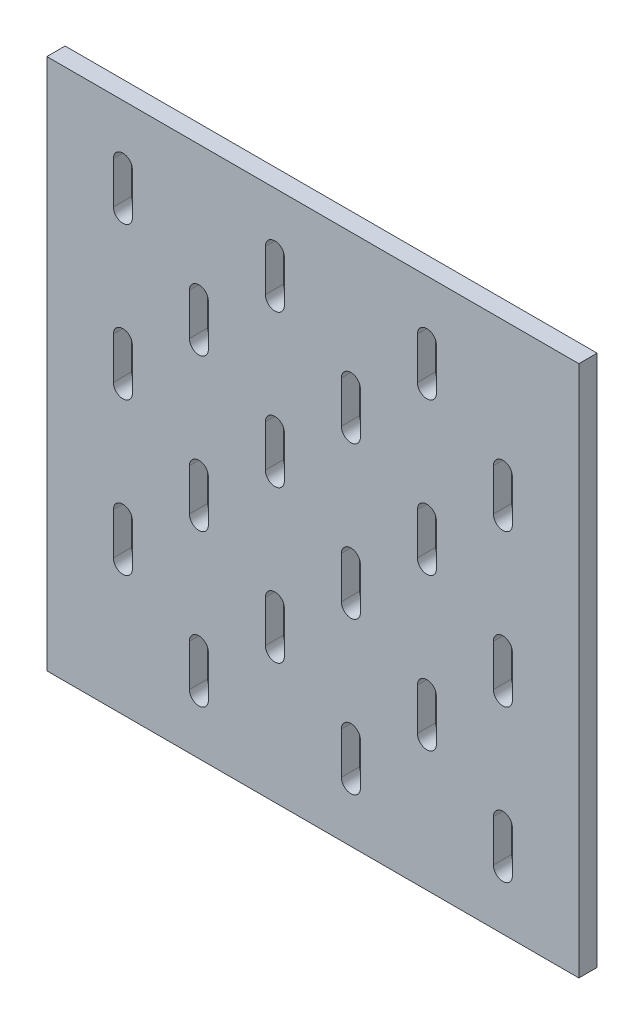
from build123d import *

# Parameters (mm, degrees)
SKETCH_1_W      = 350
SKETCH_1_H      = 350
EXTRUDE_1_DEPTH = 12


with BuildPart() as part:
    # Эскиз1 → Бобышка-Вытянуть1 (new body)
    with BuildSketch(Plane.XY):
        with Locations((75, 125)):
            Rectangle(SKETCH_1_W, SKETCH_1_H)
        with BuildLine():
            Line((6.25, 13.75), (6.25, -13.75))
            ThreePointArc((6.25, -13.75), (0, -20), (-6.25, -13.75))
            Line((-6.25, -13.75), (-6.25, 13.75))
            ThreePointArc((-6.25, 13.75), (0, 20), (6.25, 13.75))
        make_face(mode=Mode.SUBTRACT)
        with BuildLine():
            Line((-43.75, 63.75), (-43.75, 36.25))
            ThreePointArc((-43.75, 36.25), (-50, 30), (-56.25, 36.25))
            Line((-56.25, 36.25), (-56.25, 63.75))
            ThreePointArc((-56.25, 63.75), (-50, 70), (-43.75, 63.75))
        make_face(mode=Mode.SUBTRACT)
        with BuildLine():
            Line((106.25, 13.75), (106.25, -13.75))
            ThreePointArc((106.25, -13.75), (100, -20), (93.75, -13.75))
            Line((93.75, -13.75), (93.75, 13.75))
            ThreePointArc((93.75, 13.75), (100, 20), (106.25, 13.75))
        make_face(mode=Mode.SUBTRACT)
        with BuildLine():
            Line((56.25, 63.75), (56.25, 36.25))
            ThreePointArc((56.25, 36.25), (50, 30), (43.75, 36.25))
            Line((43.75, 36.25), (43.75, 63.75))
            ThreePointArc((43.75, 63.75), (50, 70), (56.25, 63.75))
        make_face(mode=Mode.SUBTRACT)
        with BuildLine():
            Line((206.25, 13.75), (206.25, -13.75))
            ThreePointArc((206.25, -13.75), (200, -20), (193.75, -13.75))
            Line((193.75, -13.75), (193.75, 13.75))
            ThreePointArc((193.75, 13.75), (200, 20), (206.25, 13.75))
        make_face(mode=Mode.SUBTRACT)
        with BuildLine():
            Line((156.25, 63.75), (156.25, 36.25))
            ThreePointArc((156.25, 36.25), (150, 30), (143.75, 36.25))
            Line((143.75, 36.25), (143.75, 63.75))
            ThreePointArc((143.75, 63.75), (150, 70), (156.25, 63.75))
        make_face(mode=Mode.SUBTRACT)
        with BuildLine():
            Line((106.25, 113.75), (106.25, 86.25))
            ThreePointArc((106.25, 86.25), (100, 80), (93.75, 86.25))
            Line((93.75, 86.25), (93.75, 113.75))
            ThreePointArc((93.75, 113.75), (100, 120), (106.25, 113.75))
        make_face(mode=Mode.SUBTRACT)
        with BuildLine():
            Line((56.25, 163.75), (56.25, 136.25))
            ThreePointArc((56.25, 136.25), (50, 130), (43.75, 136.25))
            Line((43.75, 136.25), (43.75, 163.75))
            ThreePointArc((43.75, 163.75), (50, 170), (56.25, 163.75))
        make_face(mode=Mode.SUBTRACT)
        with BuildLine():
            Line((206.25, 113.75), (206.25, 86.25))
            ThreePointArc((206.25, 86.25), (200, 80), (193.75, 86.25))
            Line((193.75, 86.25), (193.75, 113.75))
            ThreePointArc((193.75, 113.75), (200, 120), (206.25, 113.75))
        make_face(mode=Mode.SUBTRACT)
        with BuildLine():
            Line((156.25, 163.75), (156.25, 136.25))
            ThreePointArc((156.25, 136.25), (150, 130), (143.75, 136.25))
            Line((143.75, 136.25), (143.75, 163.75))
            ThreePointArc((143.75, 163.75), (150, 170), (156.25, 163.75))
        make_face(mode=Mode.SUBTRACT)
        with BuildLine():
            Line((106.25, 213.75), (106.25, 186.25))
            ThreePointArc((106.25, 186.25), (100, 180), (93.75, 186.25))
            Line((93.75, 186.25), (93.75, 213.75))
            ThreePointArc((93.75, 213.75), (100, 220), (106.25, 213.75))
        make_face(mode=Mode.SUBTRACT)
        with BuildLine():
            Line((56.25, 263.75), (56.25, 236.25))
            ThreePointArc((56.25, 236.25), (50, 230), (43.75, 236.25))
            Line((43.75, 236.25), (43.75, 263.75))
            ThreePointArc((43.75, 263.75), (50, 270), (56.25, 263.75))
        make_face(mode=Mode.SUBTRACT)
        with BuildLine():
            Line((206.25, 213.75), (206.25, 186.25))
            ThreePointArc((206.25, 186.25), (200, 180), (193.75, 186.25))
            Line((193.75, 186.25), (193.75, 213.75))
            ThreePointArc((193.75, 213.75), (200, 220), (206.25, 213.75))
        make_face(mode=Mode.SUBTRACT)
        with BuildLine():
            Line((156.25, 263.75), (156.25, 236.25))
            ThreePointArc((156.25, 236.25), (150, 230), (143.75, 236.25))
            Line((143.75, 236.25), (143.75, 263.75))
            ThreePointArc((143.75, 263.75), (150, 270), (156.25, 263.75))
        make_face(mode=Mode.SUBTRACT)
        with BuildLine():
            Line((6.25, 113.75), (6.25, 86.25))
            ThreePointArc((6.25, 86.25), (0, 80), (-6.25, 86.25))
            Line((-6.25, 86.25), (-6.25, 113.75))
            ThreePointArc((-6.25, 113.75), (0, 120), (6.25, 113.75))
        make_face(mode=Mode.SUBTRACT)
        with BuildLine():
            Line((-43.75, 163.75), (-43.75, 136.25))
            ThreePointArc((-43.75, 136.25), (-50, 130), (-56.25, 136.25))
            Line((-56.25, 136.25), (-56.25, 163.75))
            ThreePointArc((-56.25, 163.75), (-50, 170), (-43.75, 163.75))
        make_face(mode=Mode.SUBTRACT)
        with BuildLine():
            Line((6.25, 213.75), (6.25, 186.25))
            ThreePointArc((6.25, 186.25), (0, 180), (-6.25, 186.25))
            Line((-6.25, 186.25), (-6.25, 213.75))
            ThreePointArc((-6.25, 213.75), (0, 220), (6.25, 213.75))
        make_face(mode=Mode.SUBTRACT)
        with BuildLine():
            Line((-43.75, 263.75), (-43.75, 236.25))
            ThreePointArc((-43.75, 236.25), (-50, 230), (-56.25, 236.25))
            Line((-56.25, 236.25), (-56.25, 263.75))
            ThreePointArc((-56.25, 263.75), (-50, 270), (-43.75, 263.75))
        make_face(mode=Mode.SUBTRACT)
    extrude(amount=EXTRUDE_1_DEPTH)


solid = part.part
